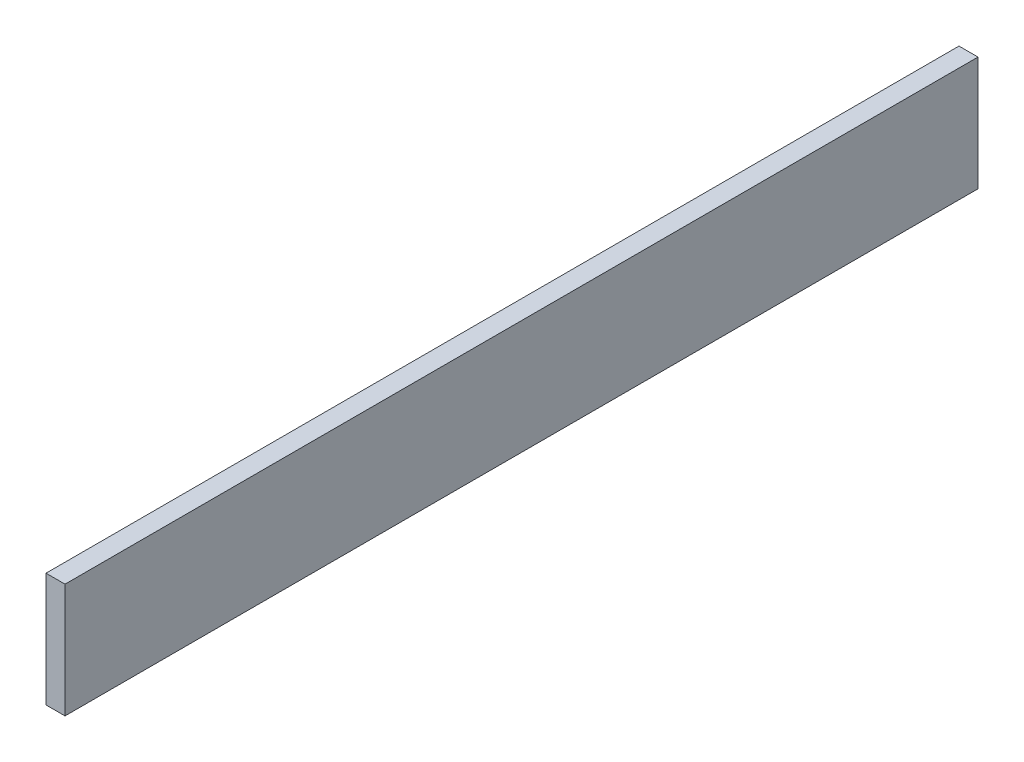
from build123d import *

# Parameters (mm, degrees)
SKETCH1_W           = 304.8
SKETCH1_H           = 38.1
BOSS_EXTRUDE1_DEPTH = 6.35


with BuildPart() as part:
    # Sketch1 → Boss-Extrude1 (new body)
    with BuildSketch(Plane(origin=(0, 0, 0), x_dir=(0, 0, -1), z_dir=(1, 0, 0))):
        with Locations((0, 19.05)):
            Rectangle(SKETCH1_W, SKETCH1_H)
    extrude(amount=BOSS_EXTRUDE1_DEPTH)


solid = part.part
